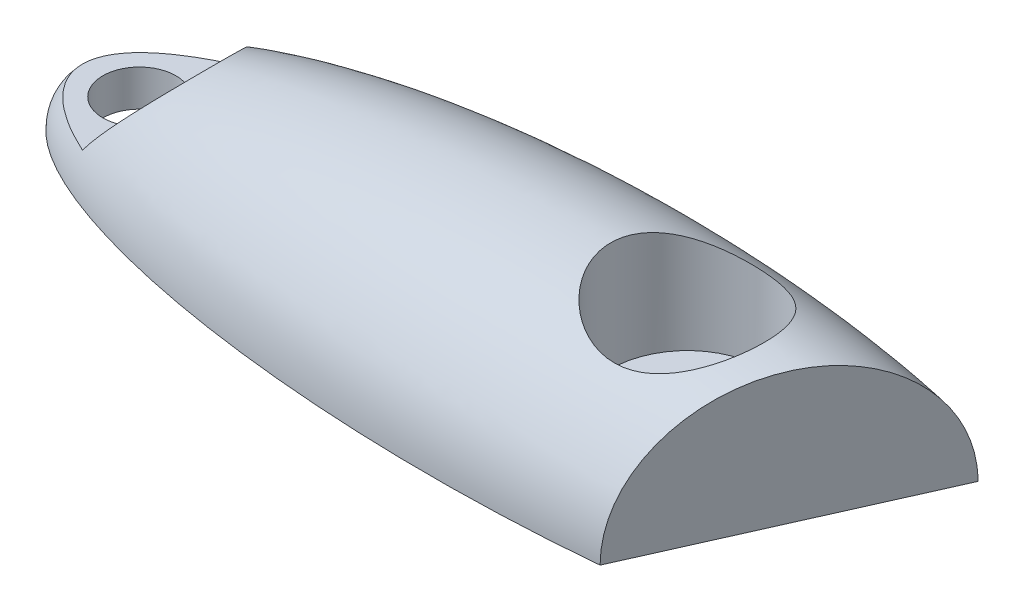
from build123d import *

# Parameters (mm, degrees)
SKETCH2_W               = 50.634745493
SKETCH2_H               = 13.07277583
CUT_EXTRUDE1_DEPTH      = 5.0000001
CUT_EXTRUDE1_DEPTH_BACK = 5.0000001
SKETCH3_R               = 1
CUT_EXTRUDE2_DEPTH      = 5.0000001
SKETCH4_R               = 2.1
CUT_EXTRUDE3_DEPTH      = 4.0000001
CUT_EXTRUDE5_DEPTH      = 5.0000001


with BuildPart() as part:
    # Sketch1 → Revolve1 (revolve)
    with BuildSketch(Plane.XY):
        with BuildLine():
            Line((-14, 0), (14, 0))
            add(Edge.make_bspline(
                [(14, 0), (14, 4), (0, 4), (-14, 4), (-14, 0)],
                knots=[0, 0, 0, 1.570796327, 1.570796327, 3.141592654, 3.141592654, 3.141592654], degree=2, weights=[1, 0.707106781, 1, 0.707106781, 1]))
        make_face()
    revolve(axis=Axis((-14, 0, 0), (1, 0, 0)))

    # Sketch2 → Cut-Extrude1 (cut, two sides)
    with BuildSketch(Plane.XY) as cut_extrude1_sk:
        with Locations((-1.598405816, -6.536387915)):
            Rectangle(SKETCH2_W, SKETCH2_H)
    extrude(amount=CUT_EXTRUDE1_DEPTH, mode=Mode.SUBTRACT)
    extrude(cut_extrude1_sk.sketch, amount=-CUT_EXTRUDE1_DEPTH_BACK, mode=Mode.SUBTRACT)

    # Sketch3 → Cut-Extrude2 (cut, through all)
    with BuildSketch(Plane.XZ):
        with Locations((-12, 0)):
            Circle(SKETCH3_R)
        with Locations((3, 0)):
            Circle(SKETCH3_R)
    extrude(amount=-CUT_EXTRUDE2_DEPTH, mode=Mode.SUBTRACT)

    # Sketch4 → Cut-Extrude3 (cut, through all)
    with BuildSketch(Plane(origin=(0, 1, 0), x_dir=(-1, 0, 0), z_dir=(0, -1, 0))):
        with Locations((12, 0)):
            Circle(SKETCH4_R)
        with Locations((-3, 0)):
            Circle(SKETCH4_R)
    extrude(amount=-CUT_EXTRUDE3_DEPTH, mode=Mode.SUBTRACT)

    # Sketch6 → Cut-Extrude5 (cut, through all)
    with BuildSketch(Plane.XZ):
        with BuildLine():
            Line((4.406700976, 3.796679392), (7.593299024, -3.360537007))
            add(Edge.make_bspline(
                [(7.593299024, -3.360537007), (14, -2.178801768), (14, 0)],
                knots=[5.285654608, 5.285654608, 5.285654608, 6.283185307, 6.283185307, 6.283185307], degree=2, weights=[1, 0.878173816, 1]))
            add(Edge.make_bspline(
                [(14, 0), (14, 2.887726136), (4.406700976, 3.796679392)],
                knots=[0, 0, 0, 1.250587947, 1.250587947, 1.250587947], degree=2, weights=[1, 0.810791081, 1]))
        make_face()
    extrude(amount=-CUT_EXTRUDE5_DEPTH, mode=Mode.SUBTRACT)


solid = part.part
